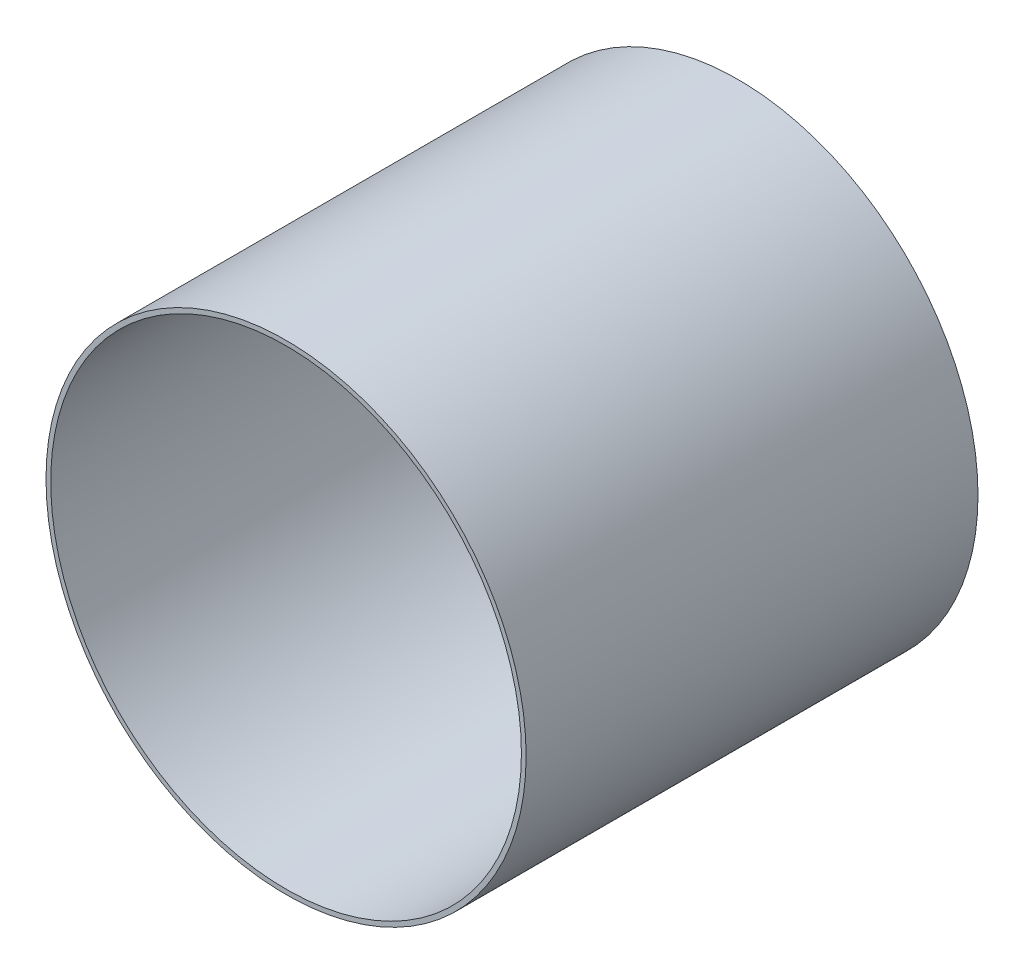
from build123d import *

# Parameters (mm, degrees)
SKETCH1_R           = 25.5
SKETCH1_R_2         = 25
BOSS_EXTRUDE1_DEPTH = 48


with BuildPart() as part:
    # Sketch1 → Boss-Extrude1 (new body)
    with BuildSketch(Plane.XY):
        Circle(SKETCH1_R)
        Circle(SKETCH1_R_2, mode=Mode.SUBTRACT)
    extrude(amount=-BOSS_EXTRUDE1_DEPTH)


solid = part.part
